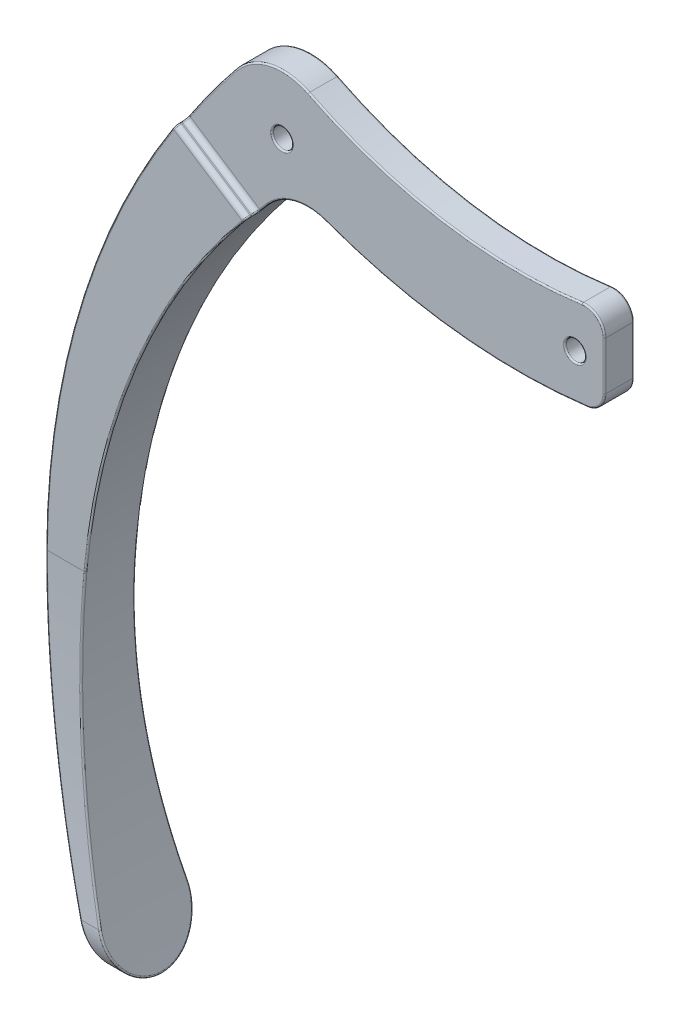
from build123d import *

# Parameters (mm, degrees)
BOSS_EXTRUDE1_DEPTH     = 5
CUT_EXTRUDE2_DEPTH      = 96.82755078110861
CUT_EXTRUDE2_DEPTH_BACK = 96.82755078110861
SKETCH7_R               = 1.0000000000000016
SKETCH7_R_2             = 0.9999999999999983
BOSS_EXTRUDE3_DEPTH     = 1.5
FILLET2_R               = 2
FILLET3_R               = 0.5
FILLET4_R               = 0.15


with BuildPart() as part:
    # Sketch3 → Boss-Extrude1 (new, symmetric)
    with BuildSketch(Plane.XY):
        with BuildLine():
            Line((-47.88, -77.95999999999992), (-46.07999999999999, -77.96))
            ThreePointArc((-46.07999999999999, -77.96), (-51.02877546851526, -39.646396920490716), (-35.18444730777396, -4.413176450220042))
            Line((-35.18444730777396, -4.413176450220042), (-42.3702949370752, 0.2864101259674179))
            ThreePointArc((-42.3702949370752, 0.2864101259674179), (-55.30033993930632, -38.12031082762163), (-47.88, -77.95999999999992))
        make_face()
    extrude(amount=BOSS_EXTRUDE1_DEPTH, both=True)

    # Sketch4 → Cut-Extrude2 (cut, two sides: drawn at the far end of the back side and taken through both)
    with BuildSketch(Plane(origin=(0, 0, 0), x_dir=(0, 0, -1), z_dir=(1, 0, 0)).offset(-CUT_EXTRUDE2_DEPTH_BACK)):
        with BuildLine():
            Line((-2.625, 4.986410125967417), (-2.6249999999999885, -43.539815135072885))
            ThreePointArc((-2.6249999999999885, -43.539815135072885), (-3.0851451389839895, -58.02079841006886), (-4.463723991120625, -72.44335471982497))
            ThreePointArc((-4.463723991120625, -72.44335471982497), (-0.00025346812432995, -77.51358986689411), (4.4637882012124015, -72.44385757310806))
            ThreePointArc((4.4637882012124015, -72.44385757310806), (3.085160384478854, -58.007912307222554), (2.6249999999999885, -43.51358987403262))
            Line((2.6249999999999885, -43.51358987403262), (2.625, 4.986410125967417))
            Line((2.625, 4.986410125967417), (37.24795800174416, 4.986410125967417))
            Line((37.24795800174416, 4.986410125967417), (37.24795800174416, -91.61123407655643))
            Line((37.24795800174416, -91.61123407655643), (-28.93037053259634, -91.61123407655643))
            Line((-28.93037053259634, -91.61123407655643), (-28.93037053259634, 4.986410125967417))
            Line((-28.93037053259634, 4.986410125967417), (-2.625, 4.986410125967417))
        make_face()
    extrude(amount=CUT_EXTRUDE2_DEPTH + CUT_EXTRUDE2_DEPTH_BACK, mode=Mode.SUBTRACT)

    # Sketch7 → Boss-Extrude3 (add, symmetric)
    with BuildSketch(Plane.XY):
        with BuildLine():
            Line((-42.3702949370752, 0.28641012596741877), (-35.18444730777395, -4.413176450220046))
            ThreePointArc((-35.18444730777395, -4.413176450220046), (-34.657694555258956, -3.792675078543347), (-34.12386318233164, -3.1782530087791567))
            ThreePointArc((-34.12386318233164, -3.1782530087791567), (-31.417561117863197, -1.5236183421697431), (-28.249999999999996, -1.692269783589685))
            ThreePointArc((-28.249999999999996, -1.692269783589685), (-14.305044942599494, -4.907658519922649), (0, -4.5))
            Line((0, -4.5), (0, 4.5))
            ThreePointArc((0, 4.5), (-15.346652662818453, 4.149177716756277), (-29.999999999999993, 8.723260799028395))
            ThreePointArc((-29.999999999999993, 8.723260799028395), (-33.94423047686867, 9.228967570519945), (-37.33844786037803, 7.157257709831201))
            ThreePointArc((-37.33844786037803, 7.157257709831201), (-39.94529602094972, 3.7884223247805053), (-42.3702949370752, 0.28641012596741877))
        make_face()
        with Locations((-2.999999999999999, -0.4236778713920037)):
            Circle(SKETCH7_R, mode=Mode.SUBTRACT)
        with Locations((-32.69204206921829, 3.361086846464123)):
            Circle(SKETCH7_R_2, mode=Mode.SUBTRACT)
    extrude(amount=BOSS_EXTRUDE3_DEPTH, both=True)

    # Fillet2
    fillet2_edges = [part.edges().sort_by_distance(p)[0] for p in [
        (0, -4.5000000000000036, 0),
        (0, 4.5, 0),
    ]]
    fillet(fillet2_edges, radius=FILLET2_R)

    # Fillet3
    fillet3_edges = [part.edges().sort_by_distance(p)[0] for p in [
        (-38.77737112242458, -2.063383162126314, -2.6249999999999987),
        (-38.77737112242458, -2.063383162126314, 2.6249999999999987),
        (-38.777371122424576, -2.0633831621263137, 1.5),
        (-38.777371122424576, -2.0633831621263137, -1.5),
    ]]
    fillet(fillet3_edges, radius=FILLET3_R)

    # Fillet4
    fillet4_edges = [part.edges().sort_by_distance(p)[0] for p in [
        (-34.49324415055013, -3.6018780326585755, -1.5),
        (-34.49324415055013, -3.6018780326585755, 1.5),
        (-35.27948893718952, -4.52668276892279, 2.4791206011057962),
        (-35.27948892856639, -4.526682757077675, -2.479120615137429),
        (-35.08906681088947, -4.299747030041311, -1.6457586802007922),
        (-42.29002635686847, 0.40890047819020825, -1.646445570795289),
        (-35.08906681088947, -4.299747030041311, 1.6457586802007924),
        (-42.29002635686847, 0.4089004781902083, 1.6464455707952887),
        (-51.328580160341566, -58.17853435705034, -3.0960691030758865),
        (-46.269038273321165, -77.51358986611379, 0.0002668877536058),
        (-51.32709927699305, -58.191375798815386, 3.0960607486939207),
        (-54.184959552978064, -58.26127306963276, 3.100570690506734),
        (-48.087728797107104, -77.51358986587577, 0.00027097659998467),
        (-54.18727397342405, -58.24861638399946, -3.1005869292541157),
        (-52.18491186837227, -20.914008530145594, 2.6249999999999885),
        (-46.419878090773636, -22.951028836848014, -2.6249999999999867),
        (-15.184440202618342, -4.813269034903932, 1.5),
        (-33.94423047686867, 9.228967570519945, 1.5),
        (-39.797270547951356, 3.989889971935753, 1.5),
        (-31.417561117863197, -1.5236183421697422, 1.5),
        (-4.000000000000001, -0.4236778713920036, -1.5),
        (-33.69204206921829, 3.361086846464123, -1.5),
        (-15.184440202618342, -4.813269034903932, -1.5),
        (-33.94423047686867, 9.228967570519945, -1.5),
        (-39.797270547951356, 3.989889971935753, -1.5),
        (-31.417561117863197, -1.5236183421697422, -1.5),
        (-4.000000000000001, -0.4236778713920036, 1.5),
        (-33.69204206921829, 3.361086846464123, 1.5),
        (0, -0.30696768972095256, -1.5),
        (0, -0.30696768972095256, 1.5),
        (-16.48492872591084, 4.323550998030413, -1.5),
        (-0.6858689501842186, 3.6566240745492387, -1.5),
        (-0.5004843654322952, -4.086317191688762, -1.5),
        (-16.48492872591084, 4.323550998030413, 1.5),
        (-0.6858689501842186, 3.6566240745492387, 1.5),
        (-0.5004843654322952, -4.086317191688762, 1.5),
        (-42.3702949370752, 0.2864101259674161, -2.0624999999999996),
        (-35.184447307773965, -4.413176450220043, -2.062499999999999),
        (-42.3702949370752, 0.2864101259674161, 2.0625),
        (-52.181187052557945, -20.901436002184212, -2.6249999999999885),
        (-42.450340573440535, 0.16377390797920133, 2.4785544601568597),
        (-42.45034056746141, 0.1637739171583796, -2.4785544493405713),
        (-35.184447307773965, -4.413176450220043, 2.062499999999999),
        (-46.42490320292987, -22.96320067383276, 2.6249999999999867),
    ]]
    fillet(fillet4_edges, radius=FILLET4_R)


solid = part.part
